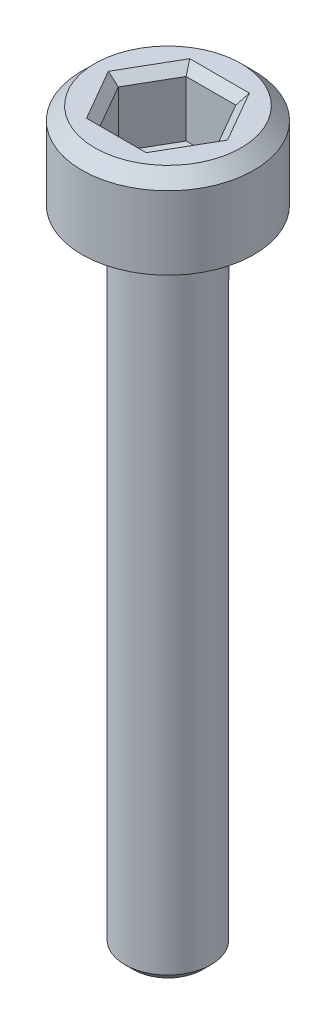
from build123d import *

# Parameters (mm, degrees)
SKETCH1_R           = 2
BOSS_EXTRUDE1_DEPTH = 2
CHAMFER1_SIZE       = 0.3
CUT_EXTRUDE1_DEPTH  = 1.5
CHAMFER2_SIZE       = 0.2
SKETCH3_R           = 1
BOSS_EXTRUDE2_DEPTH = 15
CHAMFER3_SIZE       = 0.2


with BuildPart() as part:
    # Sketch1 → Boss-Extrude1 (new body)
    with BuildSketch(Plane(origin=(0, 0, 0), x_dir=(1, 0, 0), z_dir=(0, 1, 0))):
        with Locations(Location((0, 0, 0), (0, 0, 270))):  # turned: the seam where the file's is
            Circle(SKETCH1_R)
    extrude(amount=BOSS_EXTRUDE1_DEPTH)

    # Chamfer1
    chamfer1_edges = [part.edges().sort_by_distance(p)[0] for p in [
        (0, 2, -2),
    ]]
    chamfer(chamfer1_edges, length=CHAMFER1_SIZE)

    # Sketch2 → Cut-Extrude1 (cut)
    with BuildSketch(Plane(origin=(0, 2, 0), x_dir=(1, 0, 0), z_dir=(0, 1, 0))):
        Polygon((1.154700538, 0), (0.577350269, 1), (-0.577350269, 1), (-1.154700538, 0), (-0.577350269, -1), (0.577350269, -1), align=None)
    extrude(amount=-CUT_EXTRUDE1_DEPTH, mode=Mode.SUBTRACT)

    # Chamfer2
    chamfer2_edges = [part.edges().sort_by_distance(p)[0] for p in [
        (0.866025404, 2, 0.5),
        (0.866025404, 2, -0.5),
        (0, 2, -1),
        (-0.866025404, 2, -0.5),
        (-0.866025404, 2, 0.5),
        (0, 2, 1),
    ]]
    chamfer(chamfer2_edges, length=CHAMFER2_SIZE)

    # Sketch3 → Boss-Extrude2 (add)
    with BuildSketch(Plane.XZ):
        with Locations(Location((0, 0, 0), (0, 0, 90))):  # turned: the seam where the file's is
            Circle(SKETCH3_R)
    extrude(amount=BOSS_EXTRUDE2_DEPTH)

    # Chamfer3
    chamfer3_edges = [part.edges().sort_by_distance(p)[0] for p in [
        (0, -15, -1),
    ]]
    chamfer(chamfer3_edges, length=CHAMFER3_SIZE)


solid = part.part
